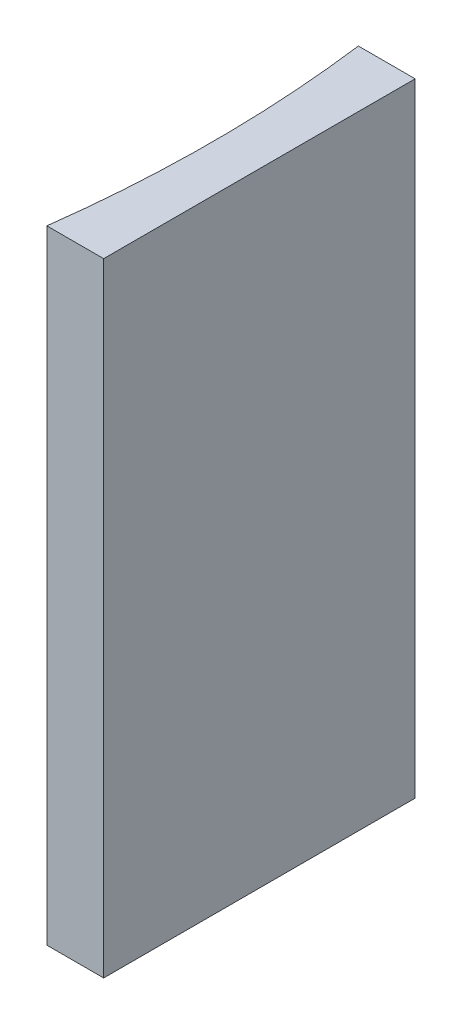
from build123d import *

# Parameters (mm, degrees)
EXTRUDE_1_DEPTH = 40


with BuildPart() as part:
    # 草图1 → 凸台-拉伸1 (new body)
    with BuildSketch(Plane(origin=(0, 0, 0), x_dir=(1, 0, 0), z_dir=(0, 1, 0))):
        with BuildLine():
            Line((0, 0), (0, -20))
            Line((0, -20), (-3.647448027, -20))
            ThreePointArc((-3.647448027, -20), (-3, -10), (-3.647448027, 0))
            Line((-3.647448027, 0), (0, 0))
        make_face()
    extrude(amount=EXTRUDE_1_DEPTH)


solid = part.part
